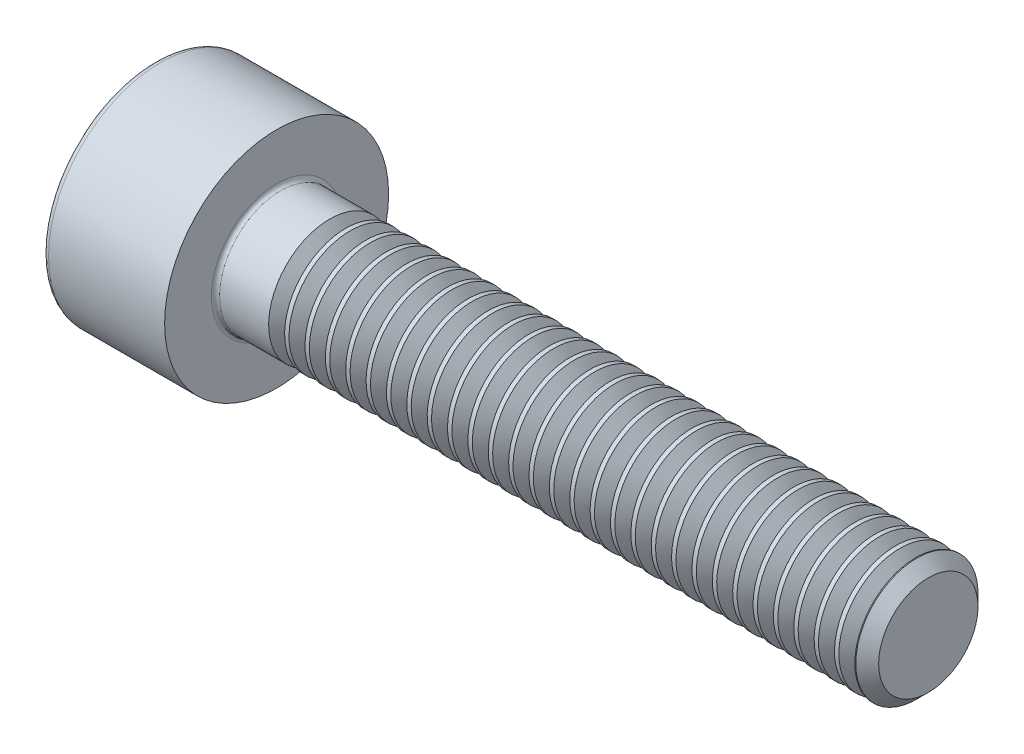
from build123d import *

# Parameters (mm, degrees)
FILLET1_R       = 0.1
FILLET2_R       = 0.15
HEX_2_DEPTH     = 1.3
THDSCHPAT_COUNT = 29
THDSCHPAT_PITCH = 0.5


with BuildPart() as part:
    # BodySke → Base-Revolve (revolve)
    with BuildSketch(Plane.XY):
        Polygon((0, 0), (0, 2.75), (3, 2.75), (3, 1.5), (18.7195, 1.5), (19, 1.2195), (19, 0), align=None)
    revolve(axis=Axis((-31.75, 0, 0), (1, 0, 0)))

    # Fillet1
    fillet1_edges = [part.edges().sort_by_distance(p)[0] for p in [
        (3, -1.5, 0),
    ]]
    fillet(fillet1_edges, radius=FILLET1_R)

    # Fillet2
    fillet2_edges = [part.edges().sort_by_distance(p)[0] for p in [
        (0, -2.75, 0),
    ]]
    fillet(fillet2_edges, radius=FILLET2_R)

    # Sketch2 → Hex-PreBroach (revolve, cut)
    with BuildSketch(Plane.XY):
        Polygon((0, 1.28), (1.3, 1.28), (2.039008345, 0), (0, 0), align=None)
    revolve(axis=Axis((0, 0, 0), (1, 0, 0)), mode=Mode.SUBTRACT)

    # Sketch3 → Hex 2 (cut)
    with BuildSketch(Plane(origin=(0, 0, 0), x_dir=(0, 0.5, 0.866025404), z_dir=(-1, 0, 0))):
        Polygon((0.739008345, 1.28), (-0.739008345, 1.28), (-1.478016689, 0), (-0.739008345, -1.28), (0.739008345, -1.28), (1.478016689, 0), align=None)
    extrude(amount=-HEX_2_DEPTH, mode=Mode.SUBTRACT)

    # ThdSchSke → ThreadSchematic (revolve, cut)
    with BuildSketch(Plane.XY):
        Polygon((4.5, -1.2195), (4.303591786, -1.5), (4.303591786, -1.875), (4.696408214, -1.875), (4.696408214, -1.5), align=None)
    threadschematic = revolve(axis=Axis((-3.175, 0, 0), (1, 0, 0)), mode=Mode.SUBTRACT)

    # ThdSchPat: ThreadSchematic ×29
    with Locations(*[(i * THDSCHPAT_PITCH, 0, 0) for i in range(1, THDSCHPAT_COUNT)]):
        add(threadschematic, mode=Mode.SUBTRACT)


solid = part.part
